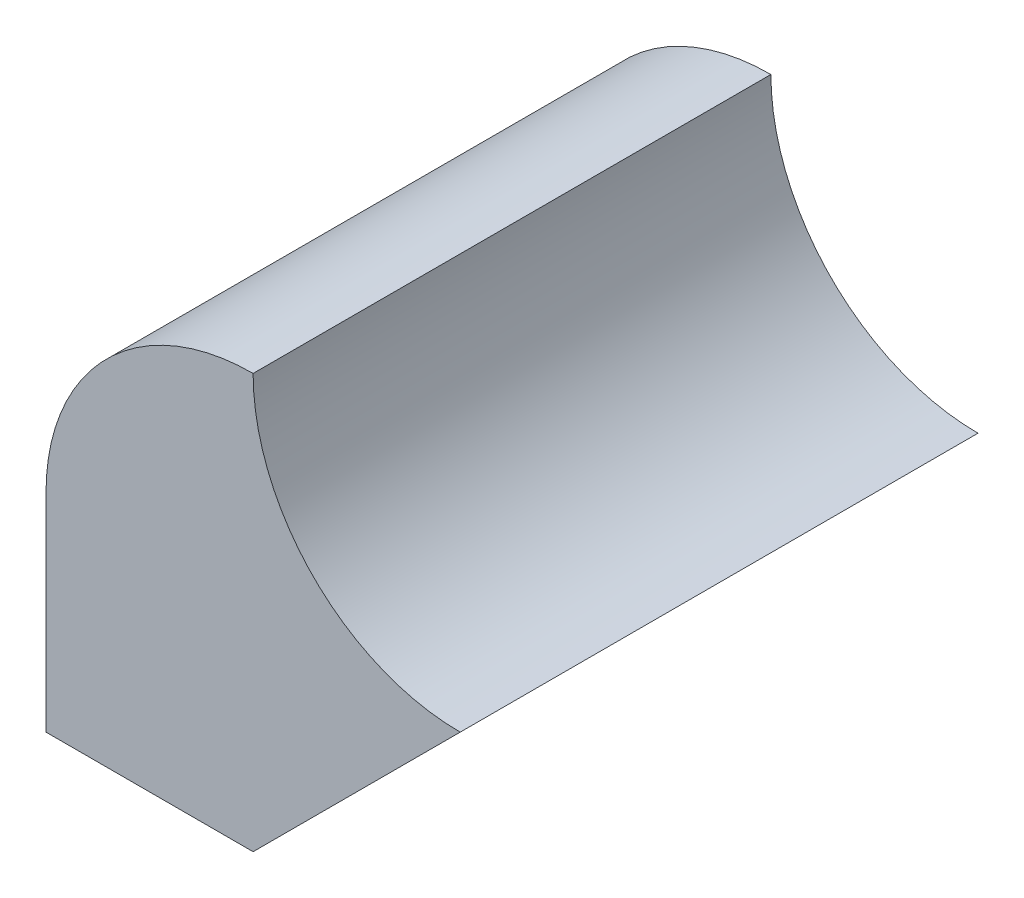
from build123d import *

# Parameters (mm, degrees)
BOSS_EXTRUDE1_DEPTH = 25


with BuildPart() as part:
    # Sketch1 → Boss-Extrude1 (new body)
    with BuildSketch(Plane.XY):
        with BuildLine():
            Line((-20, 0), (-20, -10))
            Line((-20, -10), (-10, -10))
            Line((-10, -10), (0, 0))
            ThreePointArc((0, 0), (-7.071067812, 2.928932188), (-10, 10))
            ThreePointArc((-10, 10), (-17.071067812, 7.071067812), (-20, 0))
        make_face()
    extrude(amount=BOSS_EXTRUDE1_DEPTH)


solid = part.part
